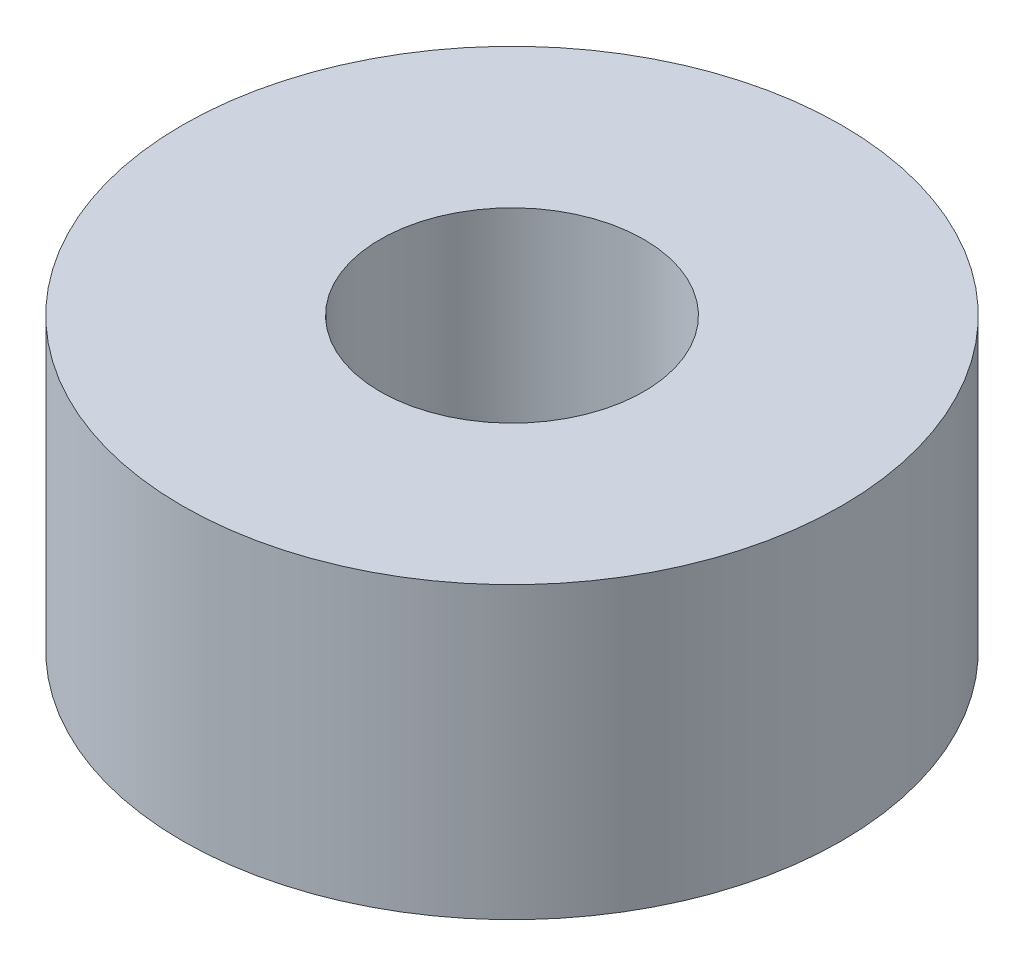
from build123d import *

# Parameters (mm, degrees)
SKETCH1_R           = 25
SKETCH1_R_2         = 10
BOSS_EXTRUDE1_DEPTH = 22


with BuildPart() as part:
    # Sketch1 → Boss-Extrude1 (new body)
    with BuildSketch(Plane(origin=(0, 0, 0), x_dir=(1, 0, 0), z_dir=(0, 1, 0))):
        Circle(SKETCH1_R)
        Circle(SKETCH1_R_2, mode=Mode.SUBTRACT)
    extrude(amount=BOSS_EXTRUDE1_DEPTH)


solid = part.part
